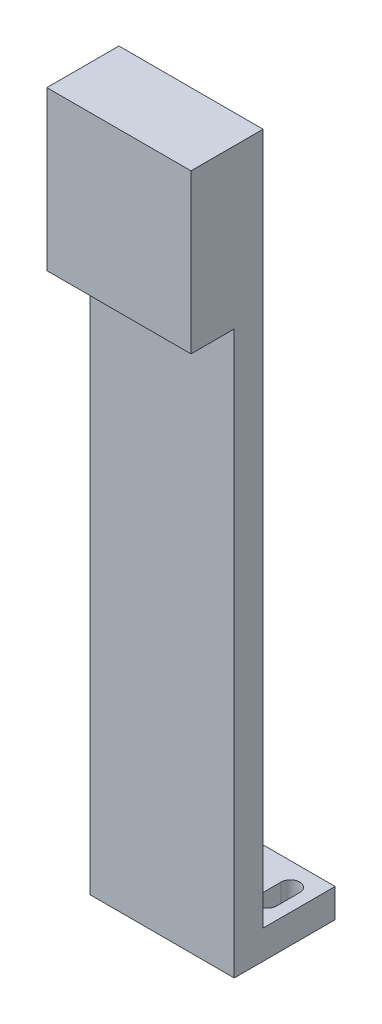
from build123d import *

# Parameters (mm, degrees)
SKETCH_1_W          = 50
SKETCH_1_H          = 35
EXTRUDE_1_DEPTH     = 250
SKETCH_2_W          = 50
SKETCH_2_H          = 25
CUT_EXTRUDE_1_DEPTH = 240
CUT_EXTRUDE_2_DEPTH = 11
SKETCH_5_W          = 50
SKETCH_5_H          = 55
EXTRUDE_2_DEPTH     = 15


with BuildPart() as part:
    # 草图1 → 凸台-拉伸1 (new body)
    with BuildSketch(Plane(origin=(0, 0, 0), x_dir=(1, 0, 0), z_dir=(0, 1, 0))):
        Rectangle(SKETCH_1_W, SKETCH_1_H)
    extrude(amount=EXTRUDE_1_DEPTH)

    # 草图2 → 切除-拉伸1 (cut)
    with BuildSketch(Plane(origin=(0, 250, 0), x_dir=(1, 0, 0), z_dir=(0, 1, 0))):
        with Locations((0, 5)):
            Rectangle(SKETCH_2_W, SKETCH_2_H)
    extrude(amount=-CUT_EXTRUDE_1_DEPTH, mode=Mode.SUBTRACT)

    # 草图3 → 切除-拉伸2 (cut, through all)
    with BuildSketch(Plane(origin=(0, 10, 0), x_dir=(1, 0, 0), z_dir=(0, 1, 0))):
        with BuildLine():
            Line((-20.7, 1.5), (-20.7, 9.5))
            ThreePointArc((-20.7, 9.5), (-17.5, 12.7), (-14.3, 9.5))
            Line((-14.3, 9.5), (-14.3, 1.5))
            ThreePointArc((-14.3, 1.5), (-17.5, -1.7), (-20.7, 1.5))
        make_face()
        with BuildLine():
            Line((20.7, 1.5), (20.7, 9.5))
            ThreePointArc((20.7, 9.5), (17.5, 12.7), (14.3, 9.5))
            Line((14.3, 9.5), (14.3, 1.5))
            ThreePointArc((14.3, 1.5), (17.5, -1.7), (20.7, 1.5))
        make_face()
    extrude(amount=-CUT_EXTRUDE_2_DEPTH, mode=Mode.SUBTRACT)

    # 草图5 → 凸台-拉伸2 (add)
    with BuildSketch(Plane.XY.offset(17.5)):
        with Locations((0, 222.5)):
            Rectangle(SKETCH_5_W, SKETCH_5_H)
    extrude(amount=EXTRUDE_2_DEPTH)


solid = part.part
